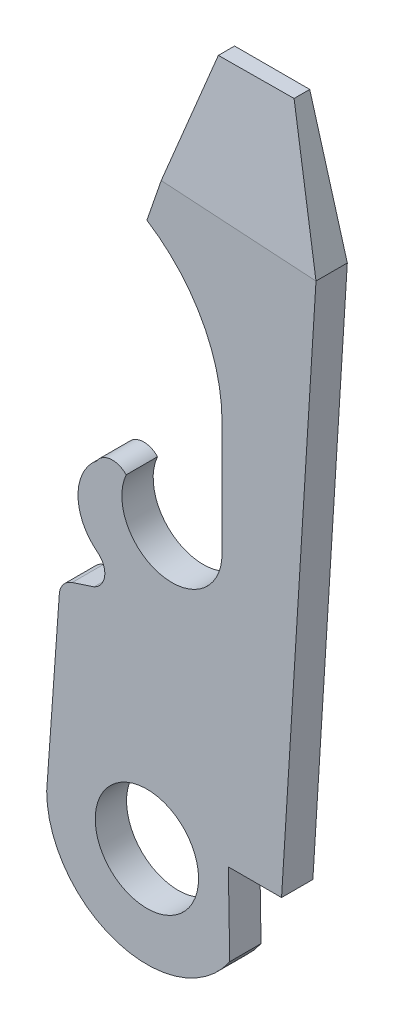
from build123d import *

# Parameters (mm, degrees)
BOSS_EXTRUDE1_DEPTH = 1.27
SKETCH2_R           = 2.0955
CUT_EXTRUDE1_DEPTH  = 2.27
CUT_EXTRUDE2_DEPTH  = 12.233456041


with BuildPart() as part:
    # Sketch1 → Boss-Extrude1 (new body)
    with BuildSketch(Plane.XY):
        with BuildLine():
            Line((48.63672497, 40.016070461), (47.23972497, 17.664070461))
            Line((47.23972497, 17.664070461), (45.08072497, 17.664070461))
            Line((45.08072497, 17.664070461), (45.138829135, 14.362070461))
            ThreePointArc((45.138829135, 14.362070461), (40.582766636, 12.764028795), (37.71472497, 16.648070461))
            Line((37.71472497, 16.648070461), (38.22272497, 23.760070461))
            ThreePointArc((38.22272497, 23.760070461), (38.367515348, 24.206944361), (38.746862194, 24.483994006))
            Line((38.746862194, 24.483994006), (39.635782378, 24.776070461))
            ThreePointArc((39.635782378, 24.776070461), (40.067551667, 25.379261916), (39.776898608, 26.061746677))
            ThreePointArc((39.776898608, 26.061746677), (38.984846047, 27.649488476), (39.74204727, 29.25414345))
            ThreePointArc((39.74204727, 29.25414345), (40.314007684, 29.599055552), (40.937994623, 29.360846875))
            ThreePointArc((40.937994623, 29.360846875), (42.372736858, 26.547570777), (44.82672497, 28.535270461))
            Line((44.82672497, 28.535270461), (44.82672497, 33.158070461))
            ThreePointArc((44.82672497, 33.158070461), (44.01481613, 36.330529444), (41.77872497, 38.722931645))
            Line((41.77872497, 38.722931645), (44.06472497, 45.350070461))
            Line((44.06472497, 45.350070461), (47.11272497, 45.350070461))
            Line((47.11272497, 45.350070461), (48.63672497, 40.016070461))
        make_face()
    extrude(amount=BOSS_EXTRUDE1_DEPTH)

    # Sketch2 → Cut-Extrude1 (cut, through all)
    with BuildSketch(Plane.XY.offset(1.27)):
        with Locations((41.77872497, 16.648070461)):
            Circle(SKETCH2_R)
    extrude(amount=-CUT_EXTRUDE1_DEPTH, mode=Mode.SUBTRACT)

    # Sketch3 → Cut-Extrude2 (cut, through all)
    with BuildSketch(Plane(origin=(45.956204144, -2.872262759, 0), x_dir=(0, 0, -1), z_dir=(0.998052578, -0.062378286, 0))):
        Polygon((-0.635, 48.200565798), (-1.27, 42.972017852), (-1.27, 48.200565798), align=None)
    extrude(amount=-CUT_EXTRUDE2_DEPTH, mode=Mode.SUBTRACT)


solid = part.part
